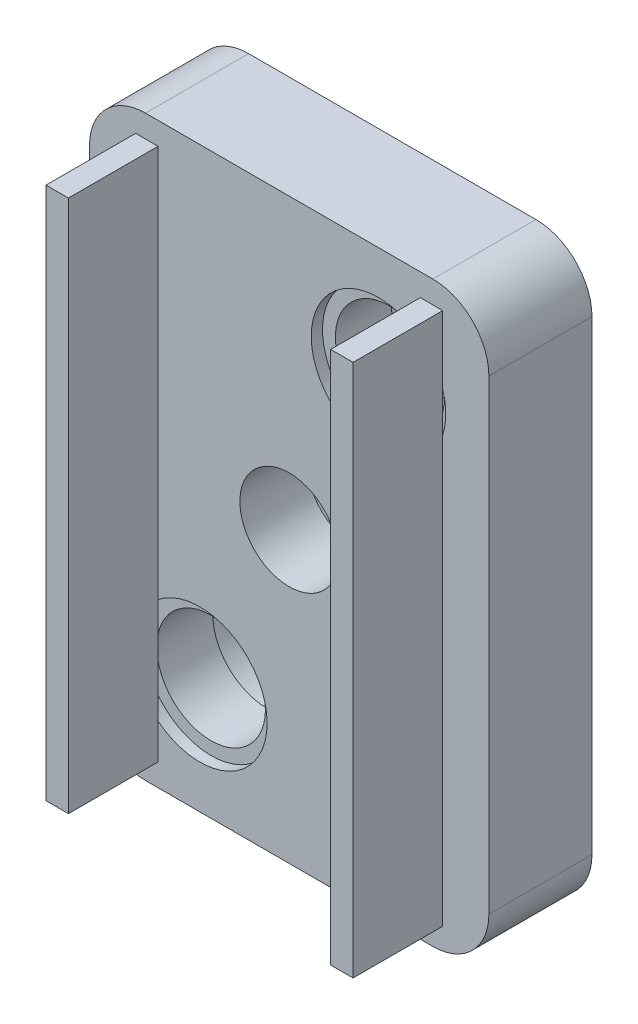
from build123d import *

# Parameters (mm, degrees)
BOSS_EXTRUDE1_DEPTH = 4.6
SKETCH4_R           = 2.425
CUT_EXTRUDE1_DEPTH  = 14.6
SKETCH5_R           = 3
CUT_EXTRUDE2_DEPTH  = 1.6
SKETCH6_R           = 3
CUT_EXTRUDE3_DEPTH  = 0.5
SKETCH7_R           = 2.2
CUT_EXTRUDE4_DEPTH  = 3
SKETCH8_W           = 1
SKETCH8_H           = 23.79
BOSS_EXTRUDE2_DEPTH = 4


with BuildPart() as part:
    # Sketch1 → Boss-Extrude1 (new body)
    with BuildSketch(Plane.XY):
        with BuildLine():
            Line((2.5, 0), (15.32, 0))
            ThreePointArc((15.32, 0), (17.087766953, 0.732233047), (17.82, 2.5))
            Line((17.82, 2.5), (17.82, 23.29))
            ThreePointArc((17.82, 23.29), (17.087766953, 25.057766953), (15.32, 25.79))
            Line((15.32, 25.79), (2.5, 25.79))
            ThreePointArc((2.5, 25.79), (0.732233047, 25.057766953), (0, 23.29))
            Line((0, 23.29), (0, 2.5))
            ThreePointArc((0, 2.5), (0.732233047, 0.732233047), (2.5, 0))
        make_face()
    extrude(amount=BOSS_EXTRUDE1_DEPTH)

    # Sketch4 → Cut-Extrude1 (cut)
    with BuildSketch(Plane.XY.offset(4.6)):
        with Locations((4.925, 4.925)):
            Circle(SKETCH4_R)
        with Locations((12.895, 20.865)):
            Circle(SKETCH4_R)
    extrude(amount=-CUT_EXTRUDE1_DEPTH, mode=Mode.SUBTRACT)

    # Sketch5 → Cut-Extrude2 (cut)
    with BuildSketch(Plane(origin=(0, 0, 0), x_dir=(-1, 0, 0), z_dir=(0, 0, -1))):
        with Locations((-12.895, 20.865)):
            Circle(SKETCH5_R)
        with Locations((-4.925, 4.925)):
            Circle(SKETCH5_R)
    extrude(amount=-CUT_EXTRUDE2_DEPTH, mode=Mode.SUBTRACT)

    # Sketch6 → Cut-Extrude3 (cut)
    with BuildSketch(Plane.XY.offset(4.6)):
        with Locations((4.925, 4.925)):
            Circle(SKETCH6_R)
        with Locations((12.895, 20.865)):
            Circle(SKETCH6_R)
    extrude(amount=-CUT_EXTRUDE3_DEPTH, mode=Mode.SUBTRACT)

    # Sketch7 → Cut-Extrude4 (cut)
    with BuildSketch(Plane.XY.offset(4.6)):
        with Locations((8.91, 12.895)):
            Circle(SKETCH7_R)
    extrude(amount=-CUT_EXTRUDE4_DEPTH, mode=Mode.SUBTRACT)

    # Sketch8 → Boss-Extrude2 (add)
    with BuildSketch(Plane.XY.offset(4.6)):
        with Locations((2.56, 12.895)):
            Rectangle(SKETCH8_W, SKETCH8_H)
        with Locations((15.26, 12.895)):
            Rectangle(SKETCH8_W, SKETCH8_H)
    extrude(amount=BOSS_EXTRUDE2_DEPTH)


solid = part.part
